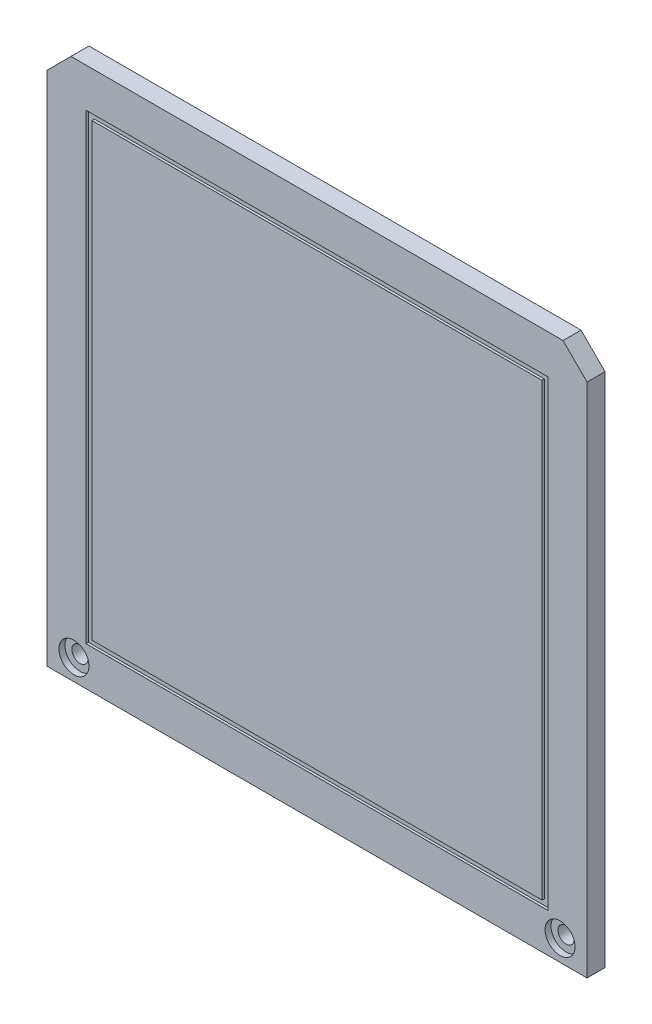
from build123d import *

# Parameters (mm, degrees)
SKETCH1_W           = 90
SKETCH1_H           = 90
BOSS_EXTRUDE1_DEPTH = 3
SKETCH2_R           = 1.35
CUT_EXTRUDE1_DEPTH  = 4
SKETCH3_W           = 77
SKETCH3_H           = 77
SKETCH3_W_2         = 75
SKETCH3_H_2         = 75
CUT_EXTRUDE2_DEPTH  = 0.4
SKETCH4_W           = 77
SKETCH4_H           = 77
SKETCH4_W_2         = 75
SKETCH4_H_2         = 75
CUT_EXTRUDE3_DEPTH  = 0.4
CHAMFER1_SIZE       = 4
SKETCH5_R           = 2.5
CUT_EXTRUDE4_DEPTH  = 1


with BuildPart() as part:
    # Sketch1 → Boss-Extrude1 (new body)
    with BuildSketch(Plane.XY):
        Rectangle(SKETCH1_W, SKETCH1_H)
    extrude(amount=BOSS_EXTRUDE1_DEPTH)

    # Sketch2 → Cut-Extrude1 (cut, through all)
    with BuildSketch(Plane.XY.offset(3)):
        with Locations((-40.5, -41.5)):
            Circle(SKETCH2_R)
        with Locations((40.5, -41.5)):
            Circle(SKETCH2_R)
    extrude(amount=-CUT_EXTRUDE1_DEPTH, mode=Mode.SUBTRACT)

    # Sketch3 → Cut-Extrude2 (cut)
    with BuildSketch(Plane.XY.offset(3)):
        Rectangle(SKETCH3_W, SKETCH3_H)
        Rectangle(SKETCH3_W_2, SKETCH3_H_2, mode=Mode.SUBTRACT)
    extrude(amount=-CUT_EXTRUDE2_DEPTH, mode=Mode.SUBTRACT)

    # Sketch4 → Cut-Extrude3 (cut)
    with BuildSketch(Plane(origin=(0, 0, 0), x_dir=(-1, 0, 0), z_dir=(0, 0, -1))):
        Rectangle(SKETCH4_W, SKETCH4_H)
        Rectangle(SKETCH4_W_2, SKETCH4_H_2, mode=Mode.SUBTRACT)
    extrude(amount=-CUT_EXTRUDE3_DEPTH, mode=Mode.SUBTRACT)

    # Chamfer1
    chamfer1_edges = [part.edges().sort_by_distance(p)[0] for p in [
        (-45, 45, 1.5),
        (45, 45, 1.5),
    ]]
    chamfer(chamfer1_edges, length=CHAMFER1_SIZE)

    # Sketch5 → Cut-Extrude4 (cut)
    with BuildSketch(Plane.XY.offset(3)):
        with Locations((-40.5, -41.5)):
            Circle(SKETCH5_R)
        with Locations((40.5, -41.5)):
            Circle(SKETCH5_R)
    extrude(amount=-CUT_EXTRUDE4_DEPTH, mode=Mode.SUBTRACT)


solid = part.part
